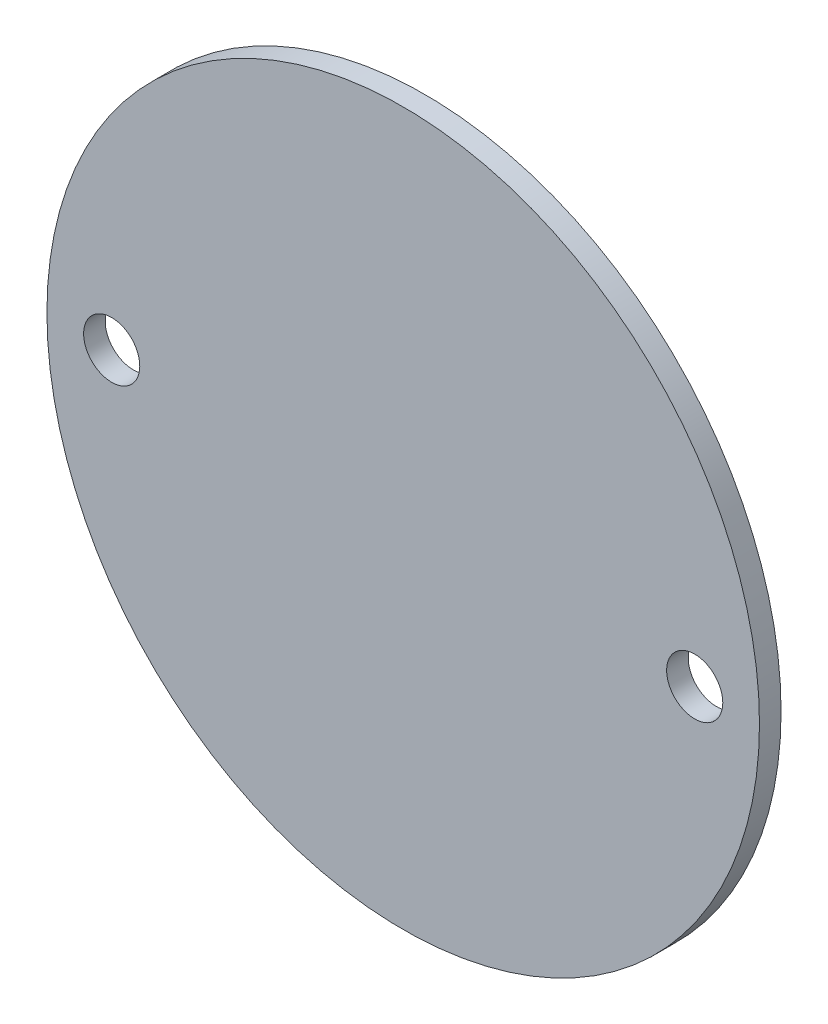
from build123d import *

# Parameters (mm, degrees)
SKETCH_1_R      = 33
SKETCH_1_R_2    = 2.6
EXTRUDE_1_DEPTH = 2


with BuildPart() as part:
    # 草图1 → 凸台-拉伸1 (new body)
    with BuildSketch(Plane.XY):
        Circle(SKETCH_1_R)
        with Locations((27, 0)):
            Circle(SKETCH_1_R_2, mode=Mode.SUBTRACT)
        with Locations((-27, 0)):
            Circle(SKETCH_1_R_2, mode=Mode.SUBTRACT)
    extrude(amount=EXTRUDE_1_DEPTH)


solid = part.part
